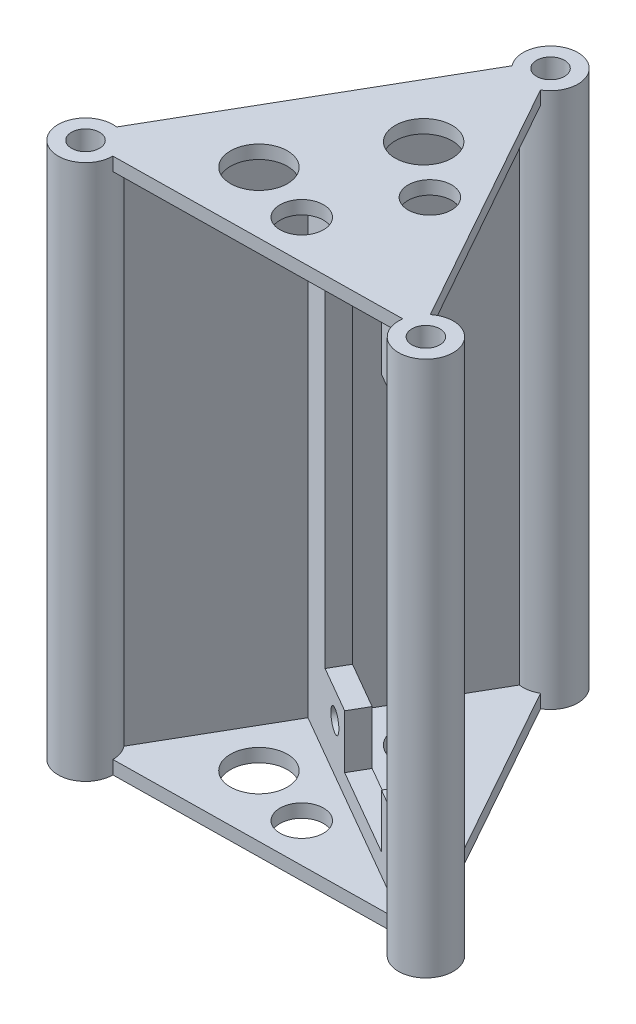
from build123d import *

# Parameters (mm, degrees)
SKETCH1_R                 = 38.1
SKETCH1_R_2               = 1.5875
BOSS_EXTRUDE1_DEPTH       = 10
BOSS_EXTRUDE2_DEPTH       = 80
RIB1_REACH                = 93.581
SKETCH3_WALL_W            = 227.849219062
SKETCH3_WALL_H            = 2
SKETCH5_R                 = 3.25
SKETCH5_R_2               = 4.25
CUT_EXTRUDE1_DEPTH        = 2
MIRROR2_COPY_1_REACH      = 93.581
MIRROR2_COPY_1_SKETCH_W   = 227.849219062
MIRROR2_COPY_1_SKETCH_H   = 2
MIRROR2_COPY_2_SKETCH_R   = 3.25
MIRROR2_COPY_2_SKETCH_R_2 = 4.25
MIRROR2_COPY_2_DEPTH      = 2
SKETCH12_R                = 1.625
CUT_EXTRUDE3_DEPTH        = 3
CUT_EXTRUDE4_DEPTH        = 3


with BuildPart() as part:
    # Sketch1 → Boss-Extrude1 (new body)
    with BuildSketch(Plane(origin=(0, 0, 0), x_dir=(1, 0, 0), z_dir=(0, 1, 0))):
        with Locations(Location((0, 0, 0), (0, 0, 270))):
            Circle(SKETCH1_R)
        with Locations(Location((0, 29.337, 0), (0, 0, 270))):
            Circle(SKETCH1_R_2, mode=Mode.SUBTRACT)
        with Locations(Location((25.406587271, -14.6685, 0), (0, 0, 270))):
            Circle(SKETCH1_R_2, mode=Mode.SUBTRACT)
        with Locations(Location((-25.406587271, -14.6685, 0), (0, 0, 270))):
            Circle(SKETCH1_R_2, mode=Mode.SUBTRACT)
    extrude(amount=BOSS_EXTRUDE1_DEPTH)


with BuildPart() as body_2:
    # Sketch2 → Boss-Extrude2 (new body)
    with BuildSketch(Plane(origin=(0, 10, 0), x_dir=(1, 0, 0), z_dir=(0, 1, 0))):
        with BuildLine():
            Line((-23.362837271, -11.128621162), (-13.453293635, 6.035211894))
            Line((-13.453293635, 6.035211894), (-12.703293635, 7.33425))
            Line((-12.703293635, 7.33425), (-11.953293635, 8.633288106))
            Line((-11.953293635, 8.633288106), (-2.04375, 25.797121162))
            ThreePointArc((-2.04375, 25.797121162), (-2.668939671, 26.241128995), (-3.200199346, 26.794092138))
            Line((-3.200199346, 26.794092138), (-24.804464136, -10.625592138))
            ThreePointArc((-24.804464136, -10.625592138), (-24.059954169, -10.809194941), (-23.362837271, -11.128621162))
        make_face()
        with BuildLine():
            Line((-12.15425553, 5.285211894), (-13.453293635, 6.035211894))
            Line((-13.453293635, 6.035211894), (-23.362837271, -11.128621162))
            ThreePointArc((-23.362837271, -11.128621162), (-22.7376476, -11.572628995), (-22.206387925, -12.125592138))
            Line((-22.206387925, -12.125592138), (-12.15425553, 5.285211894))
        make_face()
        with BuildLine():
            ThreePointArc((-21.319087271, -14.6685), (-21.547282212, -13.321866898), (-22.206387925, -12.125592138))
            Line((-22.206387925, -12.125592138), (-23.381660701, -14.161224299))
            ThreePointArc((-23.381660701, -14.161224299), (-23.334789686, -14.412939796), (-23.319087271, -14.6685))
            ThreePointArc((-23.319087271, -14.6685), (-26.663807692, -16.334949238), (-25.979736912, -12.661224299))
            Line((-25.979736912, -12.661224299), (-24.804464136, -10.625592138))
            ThreePointArc((-24.804464136, -10.625592138), (-28.502458276, -17.337439671), (-21.319087271, -14.6685))
        make_face()
        with BuildLine():
            Line((-24.362837271, -12.86067197), (-23.362837271, -11.128621162))
            ThreePointArc((-23.362837271, -11.128621162), (-24.059954169, -10.809194941), (-24.804464136, -10.625592138))
            Line((-24.804464136, -10.625592138), (-25.979736912, -12.661224299))
            ThreePointArc((-25.979736912, -12.661224299), (-25.151027067, -12.596702415), (-24.362837271, -12.86067197))
        make_face()
        with BuildLine():
            ThreePointArc((-22.206387925, -12.125592138), (-22.7376476, -11.572628995), (-23.362837271, -11.128621162))
            Line((-23.362837271, -11.128621162), (-24.362837271, -12.86067197))
            ThreePointArc((-24.362837271, -12.86067197), (-23.740138033, -13.411279579), (-23.381660701, -14.161224299))
            Line((-23.381660701, -14.161224299), (-22.206387925, -12.125592138))
        make_face()
        with BuildLine():
            ThreePointArc((4.0875, 29.337), (-1.346633102, 33.196305059), (-3.200199346, 26.794092138))
            Line((-3.200199346, 26.794092138), (-2.02492657, 28.829724299))
            ThreePointArc((-2.02492657, 28.829724299), (-0.255560204, 31.408797585), (2.0875, 29.337))
            ThreePointArc((2.0875, 29.337), (1.666449238, 28.079779579), (0.573149641, 27.329724299))
            Line((0.573149641, 27.329724299), (-0.602123135, 25.294092138))
            ThreePointArc((-0.602123135, 25.294092138), (2.668939671, 26.241128995), (4.0875, 29.337))
        make_face()
        with BuildLine():
            ThreePointArc((-3.200199346, 26.794092138), (-2.668939671, 26.241128995), (-2.04375, 25.797121162))
            Line((-2.04375, 25.797121162), (-1.04375, 27.52917197))
            ThreePointArc((-1.04375, 27.52917197), (-1.666449238, 28.079779579), (-2.02492657, 28.829724299))
            Line((-2.02492657, 28.829724299), (-3.200199346, 26.794092138))
        make_face()
        with BuildLine():
            Line((-1.04375, 27.52917197), (-2.04375, 25.797121162))
            ThreePointArc((-2.04375, 25.797121162), (-1.346633102, 25.477694941), (-0.602123135, 25.294092138))
            Line((-0.602123135, 25.294092138), (0.573149641, 27.329724299))
            ThreePointArc((0.573149641, 27.329724299), (-0.255560204, 27.265202415), (-1.04375, 27.52917197))
        make_face()
        with BuildLine():
            Line((-2.04375, 25.797121162), (-11.953293635, 8.633288106))
            Line((-11.953293635, 8.633288106), (-10.65425553, 7.883288106))
            Line((-10.65425553, 7.883288106), (-0.602123135, 25.294092138))
            ThreePointArc((-0.602123135, 25.294092138), (-1.346633102, 25.477694941), (-2.04375, 25.797121162))
        make_face()
        Polygon((-12.703293635, 7.33425), (-13.453293635, 6.035211894), (-12.15425553, 5.285211894), (-11.40425553, 6.58425), align=None)
        Polygon((-11.953293635, 8.633288106), (-12.703293635, 7.33425), (-11.40425553, 6.58425), (-10.65425553, 7.883288106), align=None)
        with BuildLine():
            Line((-10.65425553, 7.883288106), (-11.40425553, 6.58425))
            Line((-11.40425553, 6.58425), (21.866708433, -12.62475))
            ThreePointArc((21.866708433, -12.62475), (22.310716265, -11.999560329), (22.863679409, -11.468300654))
            Line((22.863679409, -11.468300654), (-10.65425553, 7.883288106))
        make_face()
        with BuildLine():
            Line((-11.40425553, 6.58425), (-12.15425553, 5.285211894))
            Line((-12.15425553, 5.285211894), (21.363679409, -14.066376865))
            ThreePointArc((21.363679409, -14.066376865), (21.547282212, -13.321866898), (21.866708433, -12.62475))
            Line((21.866708433, -12.62475), (-11.40425553, 6.58425))
        make_face()
        with BuildLine():
            ThreePointArc((22.863679409, -11.468300654), (22.310716265, -11.999560329), (21.866708433, -12.62475))
            Line((21.866708433, -12.62475), (23.59875924, -13.62475))
            ThreePointArc((23.59875924, -13.62475), (24.14936685, -13.002050762), (24.89931157, -12.64357343))
            Line((24.89931157, -12.64357343), (22.863679409, -11.468300654))
        make_face()
        with BuildLine():
            ThreePointArc((21.866708433, -12.62475), (21.547282212, -13.321866898), (21.363679409, -14.066376865))
            Line((21.363679409, -14.066376865), (23.39931157, -15.241649641))
            ThreePointArc((23.39931157, -15.241649641), (23.334789686, -14.412939796), (23.59875924, -13.62475))
            Line((23.59875924, -13.62475), (21.866708433, -12.62475))
        make_face()
        with BuildLine():
            Line((23.39931157, -15.241649641), (21.363679409, -14.066376865))
            ThreePointArc((21.363679409, -14.066376865), (25.104701229, -18.744836722), (29.494087271, -14.6685))
            ThreePointArc((29.494087271, -14.6685), (27.183314651, -10.987345824), (22.863679409, -11.468300654))
            Line((22.863679409, -11.468300654), (24.89931157, -12.64357343))
            ThreePointArc((24.89931157, -12.64357343), (26.690861039, -13.022809526), (27.494087271, -14.6685))
            ThreePointArc((27.494087271, -14.6685), (25.695955743, -16.735846642), (23.39931157, -15.241649641))
        make_face()
    extrude(amount=BOSS_EXTRUDE2_DEPTH)

    # Sketch3 wall → Rib1 (add, up to next)
    with BuildSketch(Plane(origin=(0.022296069, 90, 14.367438433), x_dir=(-0.999900512002, 0, 0.014105534336), z_dir=(0.014105534336, 0, 0.999900512002)), mode=Mode.PRIVATE) as rib1_sk1:
        with Locations((0, 1)):
            Rectangle(SKETCH3_WALL_W, SKETCH3_WALL_H)
    rib1_tool1 = extrude(rib1_sk1.sketch, amount=-RIB1_REACH, mode=Mode.PRIVATE) - body_2.part
    rib1 = rib1_tool1.solids().sort_by_distance((0.022296069, 90, 14.367438433))[0]
    add(rib1)

    # Sketch5 → Cut-Extrude1 (cut)
    with BuildSketch(Plane.XZ.offset(-88)):
        with Locations(Location((0.684201738, 8.477927826, 0), (0, 0, 270))):
            Circle(SKETCH5_R)
        with Locations(Location((-8.976052299, 5.209978634, 0), (0, 0, 270))):
            Circle(SKETCH5_R_2)
    cut_extrude1 = extrude(amount=-CUT_EXTRUDE1_DEPTH, mode=Mode.SUBTRACT)

    # Mirror1: Rib1, Cut-Extrude1 across plane
    add(rib1.mirror(Plane.ZX.offset(50)))
    add(cut_extrude1.mirror(Plane.ZX.offset(50)), mode=Mode.SUBTRACT)

    # Mirror2: Rib1, Cut-Extrude1 across plane
    add(rib1.mirror(Plane(origin=(0, 0, 0), x_dir=(0.8660254037844597, 0, 0.49999999999996353), z_dir=(0.49999999999996314, 0, -0.8660254037844598))))
    add(cut_extrude1.mirror(Plane(origin=(0, 0, 0), x_dir=(0.8660254037844597, 0, 0.49999999999996353), z_dir=(0.49999999999996314, 0, -0.8660254037844598))), mode=Mode.SUBTRACT)

    # Mirror2 copy 1 sketch → Mirror2 copy 1 (add, up to next)
    with BuildSketch(Plane(origin=(12.453714705, 10, -7.164410254), x_dir=(-0.48773450493214454, 0, -0.8729920118187576), z_dir=(0.8729920118187576, 0, -0.48773450493214465)), mode=Mode.PRIVATE) as mirror2_copy_1_sk1:
        with Locations((0, 1)):
            Rectangle(MIRROR2_COPY_1_SKETCH_W, MIRROR2_COPY_1_SKETCH_H)
    mirror2_copy_1_tool1 = extrude(mirror2_copy_1_sk1.sketch, amount=-MIRROR2_COPY_1_REACH, mode=Mode.PRIVATE) - body_2.part
    add(mirror2_copy_1_tool1.solids().sort_by_distance((12.453714705, 10, -7.164410254))[0])

    # Mirror2 copy 2 sketch → Mirror2 copy 2 (cut)
    with BuildSketch(Plane(origin=(0, 12, 0), x_dir=(0.5000000000000736, 0, 0.8660254037843962), z_dir=(0, 1, 0))):
        with Locations(Location((0.684201738, 8.477927826, 0), (0, 0, 270))):
            Circle(MIRROR2_COPY_2_SKETCH_R)
        with Locations(Location((-8.976052299, 5.209978634, 0), (0, 0, 270))):
            Circle(MIRROR2_COPY_2_SKETCH_R_2)
    extrude(amount=-MIRROR2_COPY_2_DEPTH, mode=Mode.SUBTRACT)

    # Sketch12 → Cut-Extrude3 (cut)
    with BuildSketch(Plane(origin=(-0.75, 0, 1.299038106), x_dir=(0.8660254037844608, 0, 0.49999999999996164), z_dir=(-0.49999999999996175, 0, 0.8660254037844609))):
        with Locations((-2.197056325, 80.875)):
            Circle(SKETCH12_R)
        with Locations((-2.197056325, 19.125)):
            Circle(SKETCH12_R)
        with Locations((20.802943675, 19.125)):
            Circle(SKETCH12_R)
        with Locations((20.802943675, 80.875)):
            Circle(SKETCH12_R)
    extrude(amount=-CUT_EXTRUDE3_DEPTH, mode=Mode.SUBTRACT)

    # Sketch13 → Cut-Extrude4 (cut)
    with BuildSketch(Plane(origin=(0.75, 0, -1.299038106), x_dir=(-0.8660254037844608, 0, -0.49999999999996164), z_dir=(0.49999999999996175, 0, -0.8660254037844609))):
        Polygon((6.197056325, 76.875), (6.197056325, 23.125), (-1.802943675, 23.125), (-1.802943675, 15.125), (-16.802943675, 15.125), (-16.802943675, 23.125), (-24.802943675, 23.125), (-24.802943675, 76.875), (-16.802943675, 76.875), (-16.802943675, 84.875), (-1.802943675, 84.875), (-1.802943675, 76.875), align=None)
    extrude(amount=-CUT_EXTRUDE4_DEPTH, mode=Mode.SUBTRACT)


solid = body_2.part
